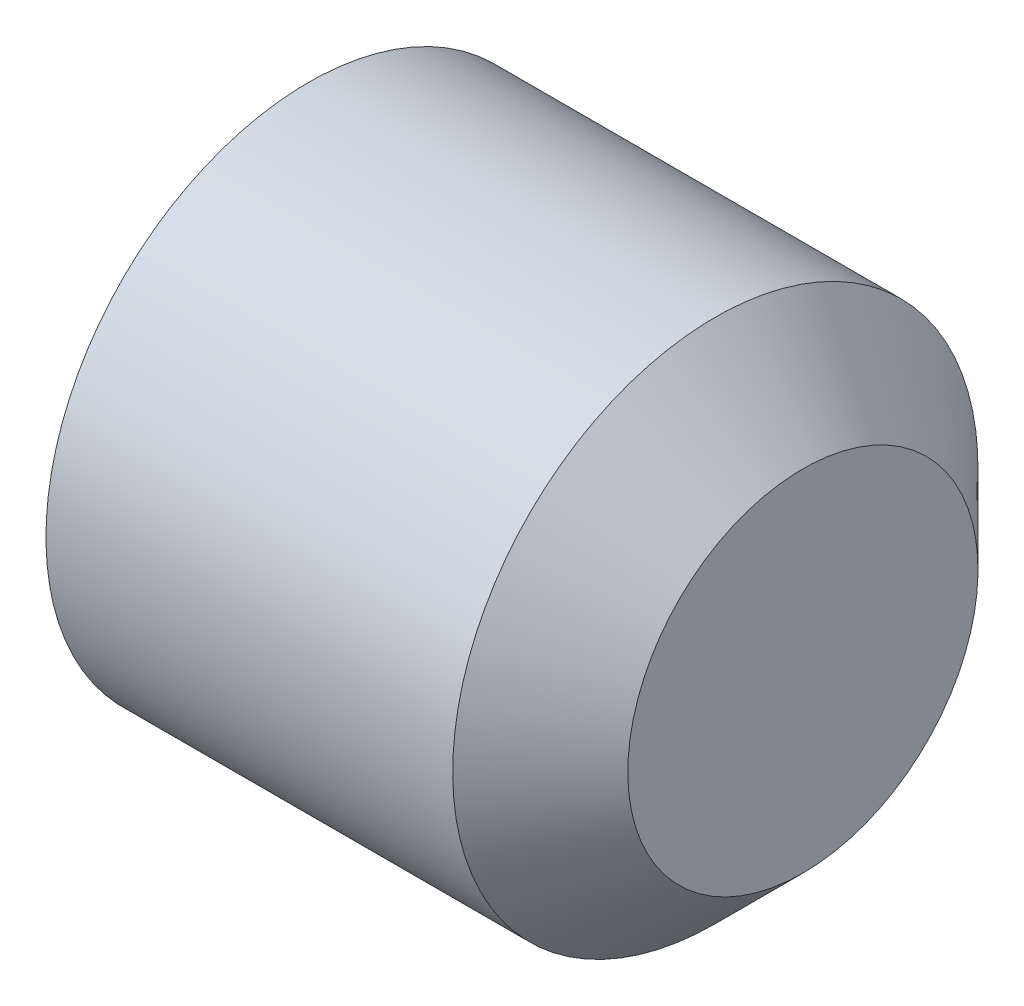
from build123d import *

# Parameters (mm, degrees)
CUT_EXTRUDE1_DEPTH = 2


with BuildPart() as part:
    # Sketch1 → Revolve1 (revolve)
    with BuildSketch(Plane.XY):
        Polygon((6, 0), (6, -2), (5, -3), (0.35420439, -3), (0, -2.3865), (0, -1.732050808), (1, 0), align=None)
    revolve(axis=Axis((1, 0, 0), (1, 0, 0)))

    # Sketch2 → Cut-Extrude1 (cut)
    with BuildSketch(Plane(origin=(0, 0, 0), x_dir=(0, 0, -1), z_dir=(1, 0, 0))):
        Polygon((-1.732050808, 0), (-0.866025404, -1.5), (0.866025404, -1.5), (1.732050808, 0), (0.866025404, 1.5), (-0.866025404, 1.5), align=None)
    extrude(amount=CUT_EXTRUDE1_DEPTH, mode=Mode.SUBTRACT)


solid = part.part
